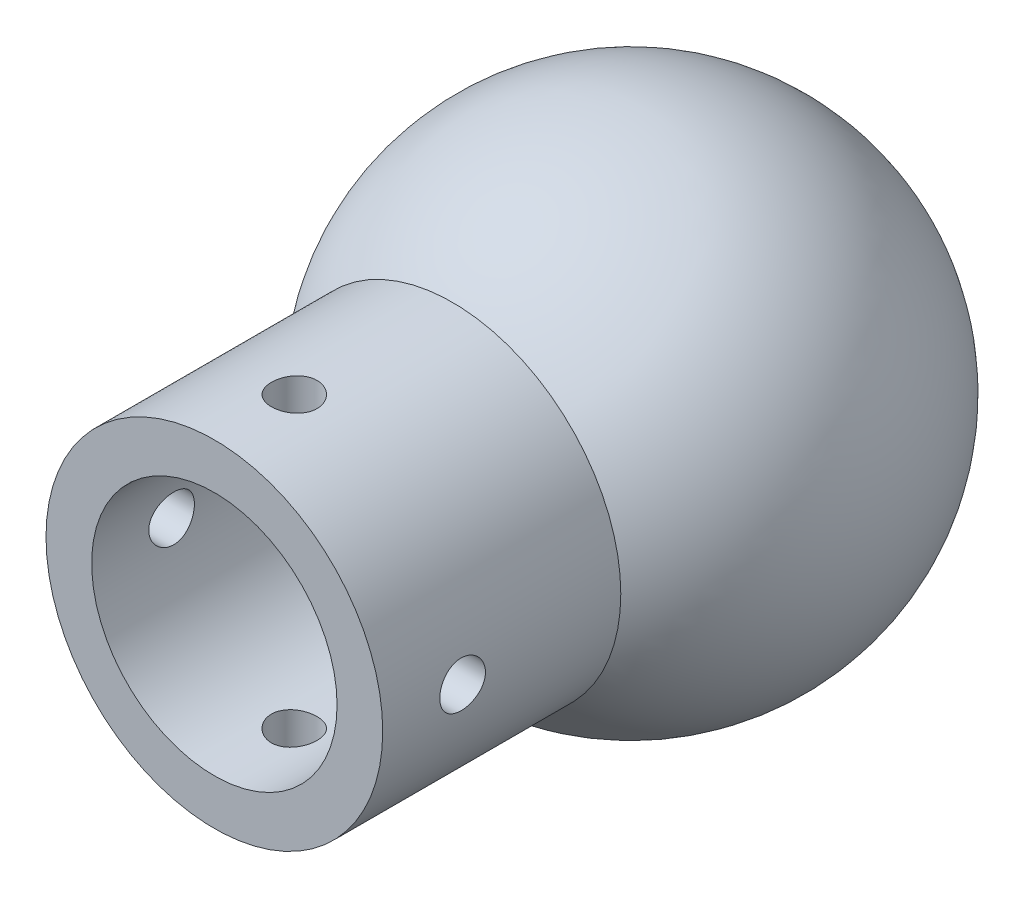
from build123d import *

# Parameters (mm, degrees)
SKETCH2_R               = 10.75
CUT_EXTRUDE1_DEPTH      = 15
BOSS_EXTRUDE1_REACH     = 45
SKETCH3_R               = 14.75
SKETCH3_R_2             = 10.75
SKETCH4_R               = 14.75
SKETCH4_R_2             = 10.75
BOSS_EXTRUDE2_DEPTH     = 15
SKETCH5_R               = 2
CUT_EXTRUDE2_DEPTH      = 22.5
CUT_EXTRUDE2_DEPTH_BACK = 22.5
SKETCH7_R               = 2
CUT_EXTRUDE3_DEPTH      = 22.5
CUT_EXTRUDE3_DEPTH_BACK = 22.5


with BuildPart() as part:
    # Sketch1 → Revolve1 (revolve)
    with BuildSketch(Plane.XY):
        with BuildLine():
            Line((0, 21.5), (0, -21.5))
            ThreePointArc((0, -21.5), (21.5, 0), (0, 21.5))
        make_face()
    revolve(axis=Axis((0, 21.5, 0), (0, -1, 0)))

    # Sketch2 → Cut-Extrude1 (cut)
    with BuildSketch(Plane.XY.offset(21.5)):
        Circle(SKETCH2_R)
    extrude(amount=-CUT_EXTRUDE1_DEPTH, mode=Mode.SUBTRACT)

    # Sketch3 → Boss-Extrude1 (add, up to next)
    with BuildSketch(Plane.XY.offset(21.5), mode=Mode.PRIVATE) as boss_extrude1_sk1:
        Circle(SKETCH3_R)
        Circle(SKETCH3_R_2, mode=Mode.SUBTRACT)
    boss_extrude1_tool1 = extrude(boss_extrude1_sk1.sketch, amount=-BOSS_EXTRUDE1_REACH, mode=Mode.PRIVATE) - part.part
    add(boss_extrude1_tool1.solids().sort_by_distance((-14.332807, 0, 21.5))[0])

    # Sketch4 → Boss-Extrude2 (add)
    with BuildSketch(Plane.XY.offset(21.5)):
        Circle(SKETCH4_R)
        Circle(SKETCH4_R_2, mode=Mode.SUBTRACT)
    extrude(amount=BOSS_EXTRUDE2_DEPTH)

    # Sketch5 → Cut-Extrude2 (cut, two sides)
    with BuildSketch(Plane(origin=(0, 0, 0), x_dir=(1, 0, 0), z_dir=(0, 1, 0))) as cut_extrude2_sk:
        with Locations((0, -29.5)):
            Circle(SKETCH5_R)
    extrude(amount=CUT_EXTRUDE2_DEPTH, mode=Mode.SUBTRACT)
    extrude(cut_extrude2_sk.sketch, amount=-CUT_EXTRUDE2_DEPTH_BACK, mode=Mode.SUBTRACT)

    # Sketch7 → Cut-Extrude3 (cut, two sides)
    with BuildSketch(Plane(origin=(0, 0, 0), x_dir=(0, 0, -1), z_dir=(1, 0, 0))) as cut_extrude3_sk:
        with Locations((-29.5, 0)):
            Circle(SKETCH7_R)
    extrude(amount=CUT_EXTRUDE3_DEPTH, mode=Mode.SUBTRACT)
    extrude(cut_extrude3_sk.sketch, amount=-CUT_EXTRUDE3_DEPTH_BACK, mode=Mode.SUBTRACT)


solid = part.part
